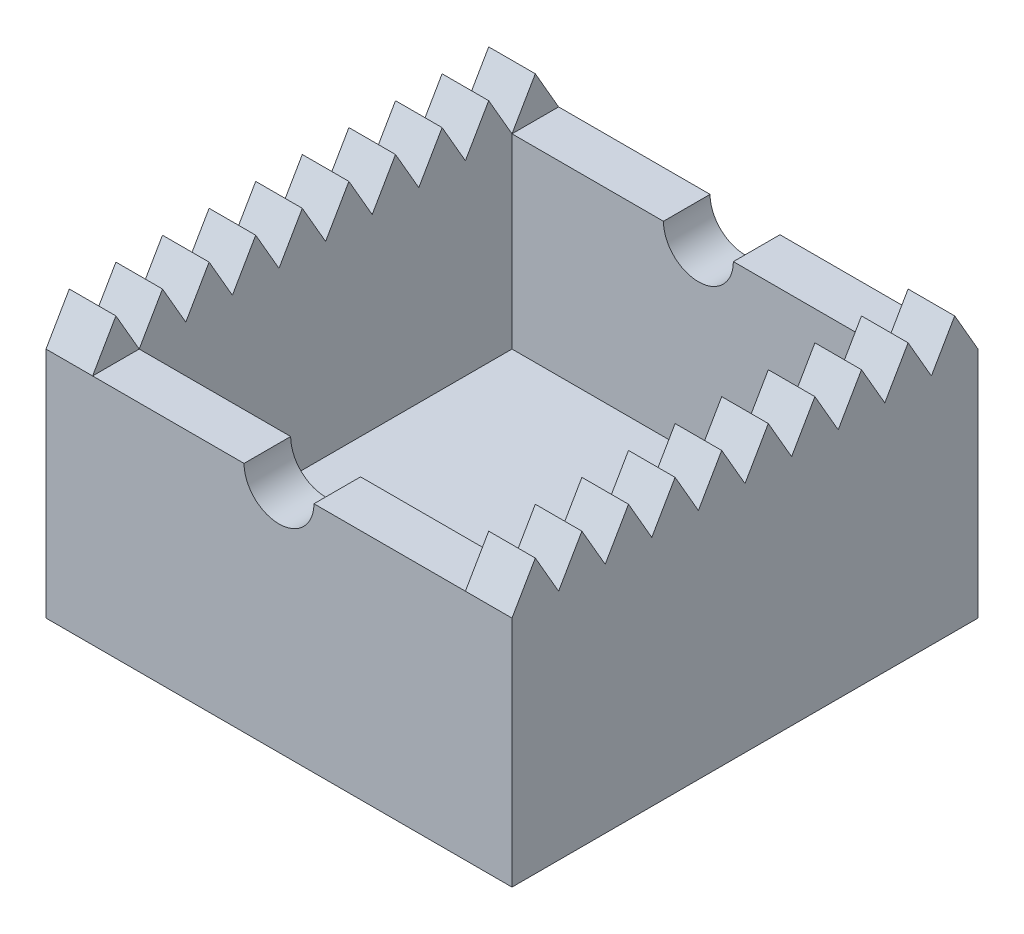
from build123d import *

# Parameters (mm, degrees)
SKETCH1_W           = 100
SKETCH1_H           = 100
BOSS_EXTRUDE1_DEPTH = 25
SKETCH4_W           = 80
SKETCH4_H           = 80
CUT_EXTRUDE2_DEPTH  = 40
SKETCH5_R           = 7.5
CUT_EXTRUDE3_DEPTH  = 100
BOSS_EXTRUDE4_DEPTH = 10
BOSS_EXTRUDE5_DEPTH = 10


with BuildPart() as part:
    # Sketch1 → Boss-Extrude1 (new body, symmetric)
    with BuildSketch(Plane(origin=(0, 0, 0), x_dir=(1, 0, 0), z_dir=(0, 1, 0))):
        Rectangle(SKETCH1_W, SKETCH1_H)
    extrude(amount=BOSS_EXTRUDE1_DEPTH, both=True)

    # Sketch4 → Cut-Extrude2 (cut)
    with BuildSketch(Plane(origin=(0, 25, 0), x_dir=(1, 0, 0), z_dir=(0, 1, 0))):
        Rectangle(SKETCH4_W, SKETCH4_H)
    extrude(amount=-CUT_EXTRUDE2_DEPTH, mode=Mode.SUBTRACT)

    # Sketch5 → Cut-Extrude3 (cut)
    with BuildSketch(Plane.XY.offset(50)):
        with Locations((0, 25)):
            Circle(SKETCH5_R)
    extrude(amount=-CUT_EXTRUDE3_DEPTH, mode=Mode.SUBTRACT)

    # Sketch7 → Boss-Extrude4 (add)
    with BuildSketch(Plane.ZY.offset(50)):
        Polygon((-45, 33.660254038), (-50, 25), (-40, 25), align=None)
        Polygon((-35, 33.660254038), (-40, 25), (-30, 25), align=None)
        Polygon((-25, 33.660254038), (-30, 25), (-20, 25), align=None)
        Polygon((-15, 33.660254038), (-20, 25), (-10, 25), align=None)
        Polygon((-5, 33.660254038), (-10, 25), (0, 25), align=None)
        Polygon((5, 33.660254038), (0, 25), (10, 25), align=None)
        Polygon((15, 33.660254038), (10, 25), (20, 25), align=None)
        Polygon((25, 33.660254038), (20, 25), (30, 25), align=None)
        Polygon((35, 33.660254038), (30, 25), (40, 25), align=None)
        Polygon((45, 33.660254038), (40, 25), (50, 25), align=None)
    extrude(amount=-BOSS_EXTRUDE4_DEPTH)

    # Sketch8 → Boss-Extrude5 (add)
    with BuildSketch(Plane(origin=(50, 0, 0), x_dir=(0, 0, -1), z_dir=(1, 0, 0))):
        Polygon((-45, 33.660254038), (-50, 25), (-40, 25), align=None)
        Polygon((-35, 33.660254038), (-40, 25), (-30, 25), align=None)
        Polygon((-25, 33.660254038), (-30, 25), (-20, 25), align=None)
        Polygon((-15, 33.660254038), (-20, 25), (-10, 25), align=None)
        Polygon((-5, 33.660254038), (-10, 25), (0, 25), align=None)
        Polygon((5, 33.660254038), (0, 25), (10, 25), align=None)
        Polygon((15, 33.660254038), (10, 25), (20, 25), align=None)
        Polygon((25, 33.660254038), (20, 25), (30, 25), align=None)
        Polygon((35, 33.660254038), (30, 25), (40, 25), align=None)
        Polygon((50, 25), (40, 25), (45, 33.660254038), align=None)
    extrude(amount=-BOSS_EXTRUDE5_DEPTH)


solid = part.part
